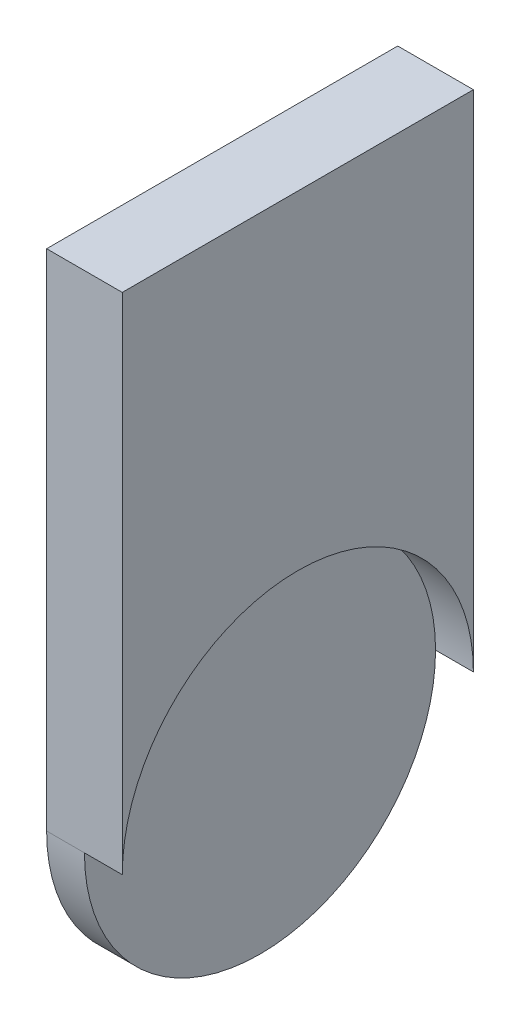
from build123d import *

# Parameters (mm, degrees)
ESQUISSE1_W             = 27.85
ESQUISSE1_H             = 40
BOSS_EXTRU_1_DEPTH      = 6
ESQUISSE2_R             = 13.925
ENL_V_MAT_EXTRU_1_DEPTH = 3


with BuildPart() as part:
    # Esquisse1 → Boss.-Extru.1 (new body)
    with BuildSketch(Plane(origin=(0, 0, 0), x_dir=(0, 0, -1), z_dir=(1, 0, 0))):
        with Locations((-1.440517241, 18.893965517)):
            Rectangle(ESQUISSE1_W, ESQUISSE1_H)
        with BuildLine():
            ThreePointArc((12.484482759, -1.106034483), (-1.440517241, -15.031034483), (-15.365517241, -1.106034483))
            Line((-15.365517241, -1.106034483), (12.484482759, -1.106034483))
        make_face()
    extrude(amount=BOSS_EXTRU_1_DEPTH)

    # Esquisse2 → Enlèv. mat.-Extru.1 (cut)
    with BuildSketch(Plane(origin=(6, 0, 0), x_dir=(0, 0, -1), z_dir=(1, 0, 0))):
        with Locations((-1.440517241, -1.106034483)):
            Circle(ESQUISSE2_R)
    extrude(amount=-ENL_V_MAT_EXTRU_1_DEPTH, mode=Mode.SUBTRACT)


solid = part.part
